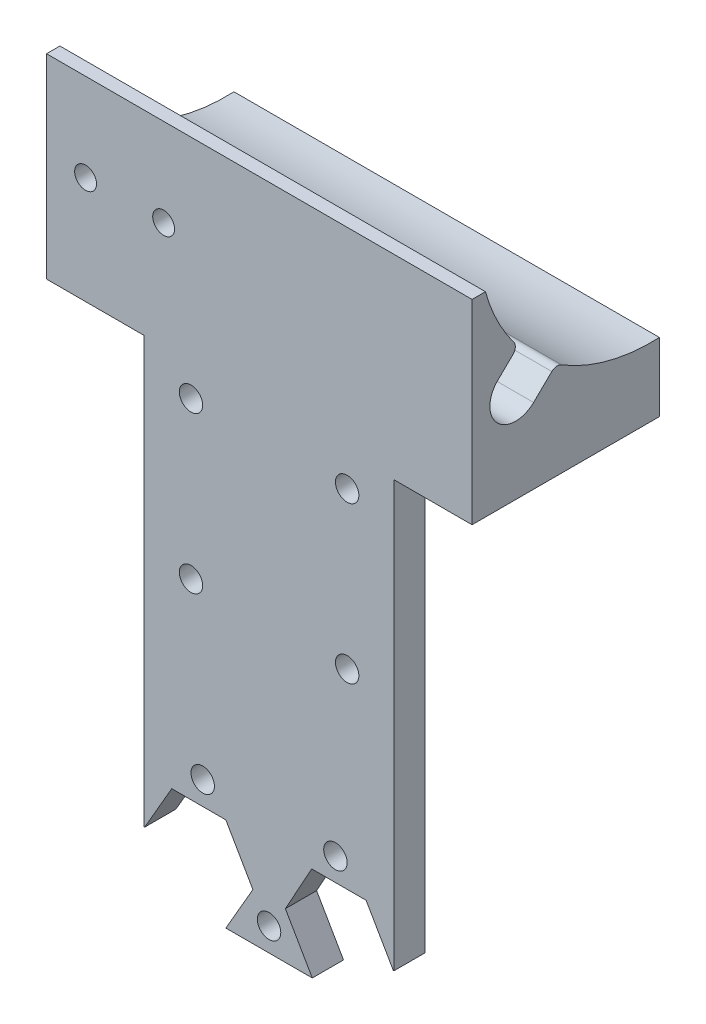
from build123d import *

# Parameters (mm, degrees)
SKETCH1_R               = 1.500000001
SKETCH1_R_2             = 1.5
BOSS_EXTRUDE2_DEPTH     = 4
SKETCH1_4_W             = 32
SKETCH1_4_H             = 25
SKETCH1_4_R             = 6.100000001
BOSS_EXTRUDE3_DEPTH     = 20
SKETCH2_R               = 1.5
CUT_EXTRUDE3_DEPTH      = 1
CUT_EXTRUDE3_DEPTH_BACK = 33
CUT_EXTRUDE4_DEPTH      = 5
CUT_EXTRUDE5_START      = -32
CUT_EXTRUDE5_DEPTH      = 5
CUT_EXTRUDE6_DEPTH      = 25
BOSS_EXTRUDE5_DEPTH     = 12.5
CUT_EXTRUDE7_REACH      = 26
SKETCH7_R               = 1.4
BOSS_EXTRUDE6_START     = -32
BOSS_EXTRUDE6_DEPTH     = 10
CUT_EXTRUDE8_DEPTH      = 43


with BuildPart() as part:
    # Sketch1 → Boss-Extrude2 (new body)
    with BuildSketch(Plane.XY):
        Polygon((-16, 39), (-16, -46.5), (-14.969293645, -46.5), (-14.969293645, -42.160880121), (-15.92820323, -40.5), (-12.464101615, -34.5), (-5.535898385, -34.5), (-2.07179677, -40.5), (-5.535898385, -46.5), (5.535898385, -46.5), (2.090853862, -40.533007852), (5.457729166, -34.432863746), (12.425340481, -34.432863746), (15.909146138, -40.466992148), (15, -42.114193768), (15, -46.5), (16, -46.5), (16, 39), align=None)
        with Locations((10, 10)):
            Circle(SKETCH1_R, mode=Mode.SUBTRACT)
        with Locations((-10, -10)):
            Circle(SKETCH1_R, mode=Mode.SUBTRACT)
        with Locations((10, -10)):
            Circle(SKETCH1_R, mode=Mode.SUBTRACT)
        with Locations((-10, 10)):
            Circle(SKETCH1_R, mode=Mode.SUBTRACT)
        with Locations((0, -43.5)):
            Circle(SKETCH1_R_2, mode=Mode.SUBTRACT)
        with Locations((-8.5, -31.5)):
            Circle(SKETCH1_R_2, mode=Mode.SUBTRACT)
        with Locations((8.5, -31.5)):
            Circle(SKETCH1_R_2, mode=Mode.SUBTRACT)
    extrude(amount=BOSS_EXTRUDE2_DEPTH)

    # Sketch1_4 → Boss-Extrude3 (add)
    with BuildSketch(Plane.XY):
        with Locations((0, 26.5)):
            Rectangle(SKETCH1_4_W, SKETCH1_4_H)
        Polygon((0, 36.969655115), (9.5, 31.484827557), (9.5, 20.515172443), (0, 15.030344885), (-9.5, 20.515172443), (-9.5, 31.484827557), align=None, mode=Mode.SUBTRACT)
        Polygon((9.5, 31.484827557), (9.5, 20.515172443), (0, 15.030344885), (-9.5, 20.515172443), (-9.5, 31.484827557), (0, 36.969655115), align=None)
        with Locations((0, 26)):
            Circle(SKETCH1_4_R, mode=Mode.SUBTRACT)
        with Locations((0, 26)):
            Circle(SKETCH1_4_R)
    extrude(amount=-BOSS_EXTRUDE3_DEPTH)

    # Sketch2 → Cut-Extrude3 (cut, two sides)
    with BuildSketch(Plane.ZY.offset(16)) as cut_extrude3_sk:
        with Locations((-1.580023732, 25.999827557)):
            Circle(SKETCH2_R)
    extrude(amount=CUT_EXTRUDE3_DEPTH, mode=Mode.SUBTRACT)
    extrude(cut_extrude3_sk.sketch, amount=-CUT_EXTRUDE3_DEPTH_BACK, mode=Mode.SUBTRACT)

    # Sketch3 → Cut-Extrude4 (cut)
    with BuildSketch(Plane.ZY.offset(16)):
        with BuildLine():
            Line((0.716979622, 28.369168308), (-1.239134605, 30.265561192))
            ThreePointArc((-1.239134605, 30.265561192), (-1.539975782, 30.904899692), (-1.343104133, 31.583501701))
            ThreePointArc((-1.343104133, 31.583501701), (0.822230527, 35.120419324), (2.287602236, 39))
            Line((2.287602236, 39), (-20, 39))
            Line((-20, 39), (-20, 22.778106647))
            ThreePointArc((-20, 22.778106647), (-13.472070231, 23.458477945), (-7.432949471, 26.028651597))
            ThreePointArc((-7.432949471, 26.028651597), (-6.799957072, 26.171029415), (-6.212814046, 25.894960789))
            Line((-6.212814046, 25.894960789), (-3.877027086, 23.630486807))
            Line((-3.877027086, 23.630486807), (0.716979622, 28.369168308))
        make_face()
        with BuildLine():
            ThreePointArc((-3.877027086, 23.630486807), (0.789317018, 23.702824203), (0.716979622, 28.369168308))
            Line((0.716979622, 28.369168308), (-3.877027086, 23.630486807))
        make_face()
    extrude(amount=-CUT_EXTRUDE4_DEPTH, mode=Mode.SUBTRACT)

    # Sketch3_4 → Cut-Extrude5 (cut)
    with BuildSketch(Plane.ZY.offset(16).offset(CUT_EXTRUDE5_START)):
        with BuildLine():
            Line((0.716979622, 28.369168308), (-1.239134605, 30.265561192))
            ThreePointArc((-1.239134605, 30.265561192), (-1.539975782, 30.904899692), (-1.343104133, 31.583501701))
            ThreePointArc((-1.343104133, 31.583501701), (0.822230527, 35.120419324), (2.287602236, 39))
            Line((2.287602236, 39), (-20, 39))
            Line((-20, 39), (-20, 22.778106647))
            ThreePointArc((-20, 22.778106647), (-13.472070231, 23.458477945), (-7.432949471, 26.028651597))
            ThreePointArc((-7.432949471, 26.028651597), (-6.799957072, 26.171029415), (-6.212814046, 25.894960789))
            Line((-6.212814046, 25.894960789), (-3.877027086, 23.630486807))
            Line((-3.877027086, 23.630486807), (0.716979622, 28.369168308))
        make_face()
        with BuildLine():
            ThreePointArc((-3.877027086, 23.630486807), (0.789317018, 23.702824203), (0.716979622, 28.369168308))
            Line((0.716979622, 28.369168308), (-3.877027086, 23.630486807))
        make_face()
    extrude(amount=CUT_EXTRUDE5_DEPTH, mode=Mode.SUBTRACT)

    # Sketch5 → Cut-Extrude6 (cut, through all)
    with BuildSketch(Plane.XY.offset(4)):
        Polygon((-14.969293645, -42.160880121), (-15.92820323, -40.5), (-16, -40.500074436), (-16, -46.5), (-14.969293645, -46.5), align=None)
        Polygon((15, -42.114193768), (15.909146138, -40.466992148), (10.36687247, -40.472738184), (10.36687247, -46.5), (15, -46.5), align=None)
        Polygon((16, -40.466897954), (15.909146138, -40.466992148), (15, -42.114193768), (15, -46.5), (16, -46.5), align=None)
        Polygon((17.825288522, -40.465005559), (16, -40.466897954), (16, -46.5), (17.916172301, -46.5), align=None)
    extrude(amount=-CUT_EXTRUDE6_DEPTH, mode=Mode.SUBTRACT)

    # Sketch8 → Boss-Extrude5 (add)
    with BuildSketch(Plane.ZY.offset(16)):
        with BuildLine():
            ThreePointArc((-1.343104133, 31.583501701), (-1.539975782, 30.904899692), (-1.239134605, 30.265561192))
            Line((-1.239134605, 30.265561192), (0.716979622, 28.369168308))
            ThreePointArc((0.716979622, 28.369168308), (0.789317018, 23.702824203), (-3.877027086, 23.630486807))
            Line((-3.877027086, 23.630486807), (-6.212814046, 25.894960789))
            ThreePointArc((-6.212814046, 25.894960789), (-6.799957072, 26.171029415), (-7.432949471, 26.028651597))
            ThreePointArc((-7.432949471, 26.028651597), (-13.472070231, 23.458477945), (-20, 22.778106647))
            Line((-20, 22.778106647), (-20, 14))
            Line((-20, 14), (0, 14))
            Line((0, 14), (4, 14))
            Line((4, 14), (4, 39))
            Line((4, 39), (2.287602236, 39))
            ThreePointArc((2.287602236, 39), (0.822230527, 35.120419324), (-1.343104133, 31.583501701))
        make_face()
    extrude(amount=BOSS_EXTRUDE5_DEPTH)

    # Sketch7 → Cut-Extrude7 (cut, up to next)
    with BuildSketch(Plane.XY.offset(4), mode=Mode.PRIVATE) as cut_extrude7_sk1:
        with Locations((-23.5, 27.75)):
            Circle(SKETCH7_R)
    cut_extrude7_tool1 = extrude(cut_extrude7_sk1.sketch, amount=-CUT_EXTRUDE7_REACH, mode=Mode.PRIVATE) & part.part
    add(cut_extrude7_tool1.solids().sort_by_distance((-23.5, 27.75, 4))[0], mode=Mode.SUBTRACT)
    # Sketch7 → Cut-Extrude7 (cut, up to next)
    with BuildSketch(Plane.XY.offset(4), mode=Mode.PRIVATE) as cut_extrude7_sk2:
        with Locations((-13.5, 27.75)):
            Circle(SKETCH7_R)
    cut_extrude7_tool2 = extrude(cut_extrude7_sk2.sketch, amount=-CUT_EXTRUDE7_REACH, mode=Mode.PRIVATE) & part.part
    add(cut_extrude7_tool2.solids().sort_by_distance((-13.5, 27.75, 4))[0], mode=Mode.SUBTRACT)

    # Sketch8_3 → Boss-Extrude6 (add)
    with BuildSketch(Plane.ZY.offset(16).offset(BOSS_EXTRUDE6_START)):
        with BuildLine():
            ThreePointArc((-1.343104133, 31.583501701), (-1.539975782, 30.904899692), (-1.239134605, 30.265561192))
            Line((-1.239134605, 30.265561192), (0.716979622, 28.369168308))
            ThreePointArc((0.716979622, 28.369168308), (0.789317018, 23.702824203), (-3.877027086, 23.630486807))
            Line((-3.877027086, 23.630486807), (-6.212814046, 25.894960789))
            ThreePointArc((-6.212814046, 25.894960789), (-6.799957072, 26.171029415), (-7.432949471, 26.028651597))
            ThreePointArc((-7.432949471, 26.028651597), (-13.472070231, 23.458477945), (-20, 22.778106647))
            Line((-20, 22.778106647), (-20, 14))
            Line((-20, 14), (0, 14))
            Line((0, 14), (4, 14))
            Line((4, 14), (4, 39))
            Line((4, 39), (2.287602236, 39))
            ThreePointArc((2.287602236, 39), (0.822230527, 35.120419324), (-1.343104133, 31.583501701))
        make_face()
    extrude(amount=-BOSS_EXTRUDE6_DEPTH)

    # Sketch8_4 → Cut-Extrude8 (cut, through all)
    with BuildSketch(Plane.ZY.offset(16)):
        with BuildLine():
            ThreePointArc((-1.343104133, 31.583501701), (-4.126373378, 28.519223025), (-7.432949471, 26.028651597))
            ThreePointArc((-7.432949471, 26.028651597), (-13.472070231, 23.458477945), (-20, 22.778106647))
            Line((-20, 22.778106647), (-20, 39))
            Line((-20, 39), (2.287602236, 39))
            ThreePointArc((2.287602236, 39), (0.822230527, 35.120419324), (-1.343104133, 31.583501701))
        make_face()
    extrude(amount=-CUT_EXTRUDE8_DEPTH, mode=Mode.SUBTRACT)


solid = part.part
